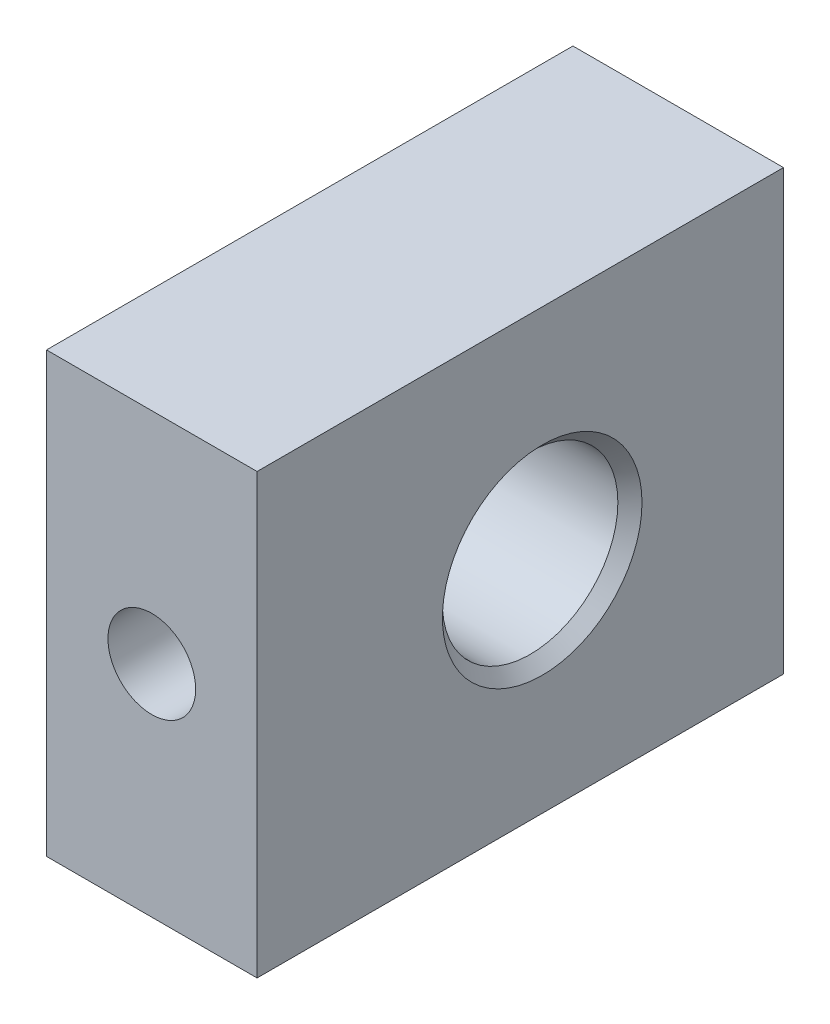
from build123d import *

# Parameters (mm, degrees)
SKETCH_1_W          = 4.8
SKETCH_1_H          = 10
EXTRUDE_1_DEPTH     = 12
CUT_EXTRUDE_1_REACH = 14
SKETCH_4_R          = 1


with BuildPart() as part:
    # Эскиз1 → Бобышка-Вытянуть1 (new body)
    with BuildSketch(Plane.XY):
        Rectangle(SKETCH_1_W, SKETCH_1_H)
    extrude(amount=EXTRUDE_1_DEPTH)

    # Эскиз2 → Отверстие обработанное метчиком M41 (revolve, cut)
    with BuildSketch(Plane(origin=(2.4, 0, 5.5), x_dir=(0, 0, -1), z_dir=(0, 1, 0))):
        Polygon((0, 0), (0, 4.8), (2.275, 4.8), (2, 4.525), (2, 0.275), (2.275, 0), align=None)
    revolve(axis=Axis((8.75, 0, 5.5), (-1, 0, 0)), mode=Mode.SUBTRACT)

    # Эскиз4 → Вырез-Вытянуть1 (cut, up to next)
    with BuildSketch(Plane.XY.offset(12), mode=Mode.PRIVATE) as cut_extrude_1_sk1:
        Circle(SKETCH_4_R)
    cut_extrude_1_tool1 = extrude(cut_extrude_1_sk1.sketch, amount=-CUT_EXTRUDE_1_REACH, mode=Mode.PRIVATE) & part.part
    add(cut_extrude_1_tool1.solids().sort_by_distance((0, 0, 12))[0], mode=Mode.SUBTRACT)


solid = part.part
